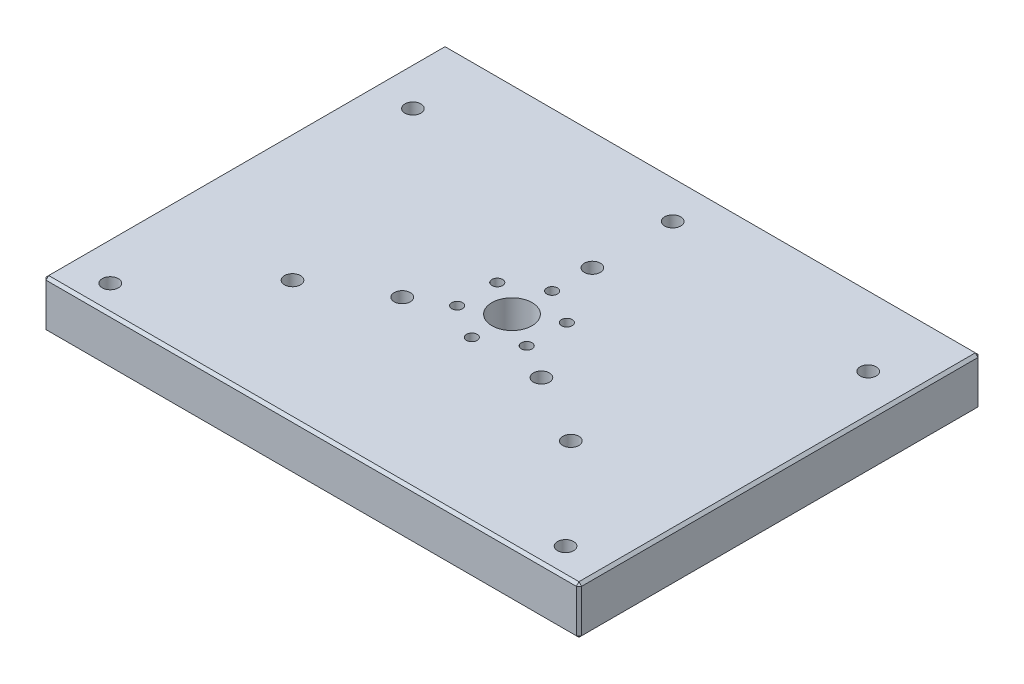
from build123d import *

# Parameters (mm, degrees)
SKETCH1_W                = 200
SKETCH1_H                = 150
SKETCH1_R                = 7.5
SKETCH1_R_2              = 2
BOSS_EXTRUDE1_DEPTH      = 8
BOSS_EXTRUDE1_DEPTH_BACK = 10
SKETCH2_R                = 3
CUT_EXTRUDE2_DEPTH       = 10
CUT_EXTRUDE2_DEPTH_BACK  = 10
CHAMFER2_SIZE            = 1


with BuildPart() as part:
    # Sketch1 → Boss-Extrude1 (new body, two sides)
    with BuildSketch(Plane(origin=(0, 0, 0), x_dir=(1, 0, 0), z_dir=(0, 1, 0))) as boss_extrude1_sk:
        Rectangle(SKETCH1_W, SKETCH1_H)
        Circle(SKETCH1_R, mode=Mode.SUBTRACT)
        with Locations((0, 15)):
            Circle(SKETCH1_R_2, mode=Mode.SUBTRACT)
        with Locations((12.990381057, 7.5)):
            Circle(SKETCH1_R_2, mode=Mode.SUBTRACT)
        with Locations((12.990381057, -7.5)):
            Circle(SKETCH1_R_2, mode=Mode.SUBTRACT)
        with Locations((0, -15)):
            Circle(SKETCH1_R_2, mode=Mode.SUBTRACT)
        with Locations((-12.990381057, -7.5)):
            Circle(SKETCH1_R_2, mode=Mode.SUBTRACT)
        with Locations((-12.990381057, 7.5)):
            Circle(SKETCH1_R_2, mode=Mode.SUBTRACT)
    extrude(amount=BOSS_EXTRUDE1_DEPTH)
    extrude(boss_extrude1_sk.sketch, amount=-BOSS_EXTRUDE1_DEPTH_BACK)

    # Sketch2 → Cut-Extrude2 (cut, two sides)
    with BuildSketch(Plane(origin=(0, 0, 0), x_dir=(1, 0, 0), z_dir=(0, 1, 0))) as cut_extrude2_sk:
        with Locations((-25.980762114, -15)):
            Circle(SKETCH2_R)
        with Locations((0, 30)):
            Circle(SKETCH2_R)
        with Locations((25.980762114, -15)):
            Circle(SKETCH2_R)
        with Locations((85, 48)):
            Circle(SKETCH2_R)
        with Locations((85, -65)):
            Circle(SKETCH2_R)
        with Locations((-51.961524227, -30)):
            Circle(SKETCH2_R)
        with Locations((-85, -65)):
            Circle(SKETCH2_R)
        with Locations((-85, 48)):
            Circle(SKETCH2_R)
        with Locations((0, 60)):
            Circle(SKETCH2_R)
        with Locations((51.961524227, -30)):
            Circle(SKETCH2_R)
    extrude(amount=CUT_EXTRUDE2_DEPTH, mode=Mode.SUBTRACT)
    extrude(cut_extrude2_sk.sketch, amount=-CUT_EXTRUDE2_DEPTH_BACK, mode=Mode.SUBTRACT)

    # Chamfer2
    chamfer2_edges = [part.edges().sort_by_distance(p)[0] for p in [
        (-100, -10, 0),
        (0, -10, 75),
        (100, 8, 0),
        (0, 8, -75),
        (-100, 8, 0),
        (0, 8, 75),
        (100, -10, 0),
        (0, -10, -75),
        (100, -1, 75),
        (-100, -1, 75),
        (-100, -1, -75),
        (100, -1, -75),
    ]]
    chamfer(chamfer2_edges, length=CHAMFER2_SIZE)


solid = part.part
